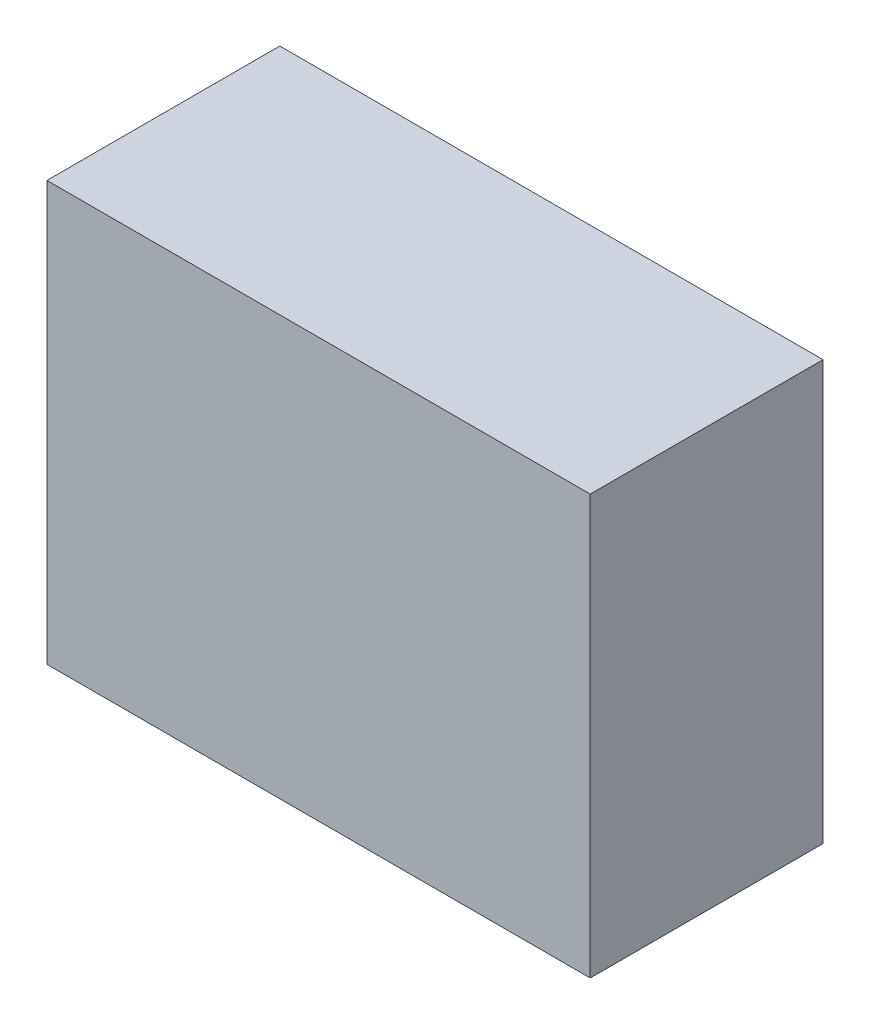
from build123d import *

# Parameters (mm, degrees)
SKETCH1_W           = 70
SKETCH1_H           = 54
BOSS_EXTRUDE1_DEPTH = 30


with BuildPart() as part:
    # Sketch1 → Boss-Extrude1 (new body)
    with BuildSketch(Plane.XY):
        with Locations((35, 27)):
            Rectangle(SKETCH1_W, SKETCH1_H)
    extrude(amount=BOSS_EXTRUDE1_DEPTH)


solid = part.part
